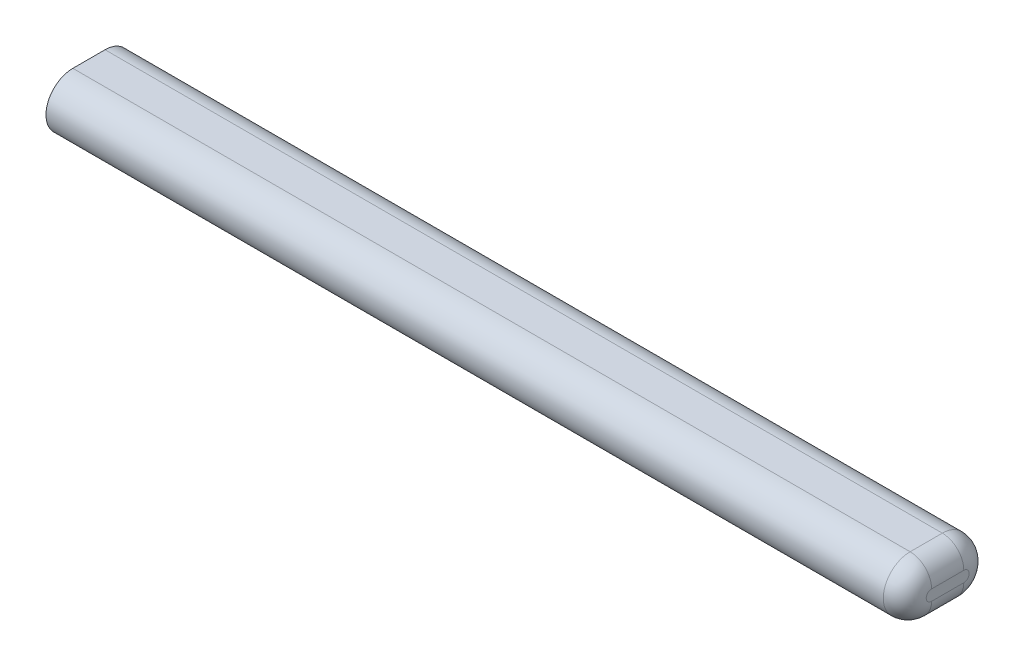
from build123d import *

# Parameters (mm, degrees)
SALIENTE_EXTRUIR1_DEPTH = 400
REDONDEO1_R             = 10


with BuildPart() as part:
    # Croquis1 → Saliente-Extruir1 (new body)
    with BuildSketch(Plane(origin=(0, 0, 0), x_dir=(0, 0, -1), z_dir=(1, 0, 0))):
        with BuildLine():
            Line((0, 12.5), (15, 12.5))
            ThreePointArc((15, 12.5), (27.5, 0), (15, -12.5))
            Line((15, -12.5), (0, -12.5))
            ThreePointArc((0, -12.5), (-12.5, 0), (0, 12.5))
        make_face()
    extrude(amount=SALIENTE_EXTRUIR1_DEPTH)

    # Redondeo1
    redondeo1_edges = [part.edges().sort_by_distance(p)[0] for p in [
        (400, 0, -27.5),
        (400, 12.5, -7.5),
        (400, 0, 12.5),
        (400, -12.5, -7.5),
    ]]
    fillet(redondeo1_edges, radius=REDONDEO1_R)


solid = part.part
